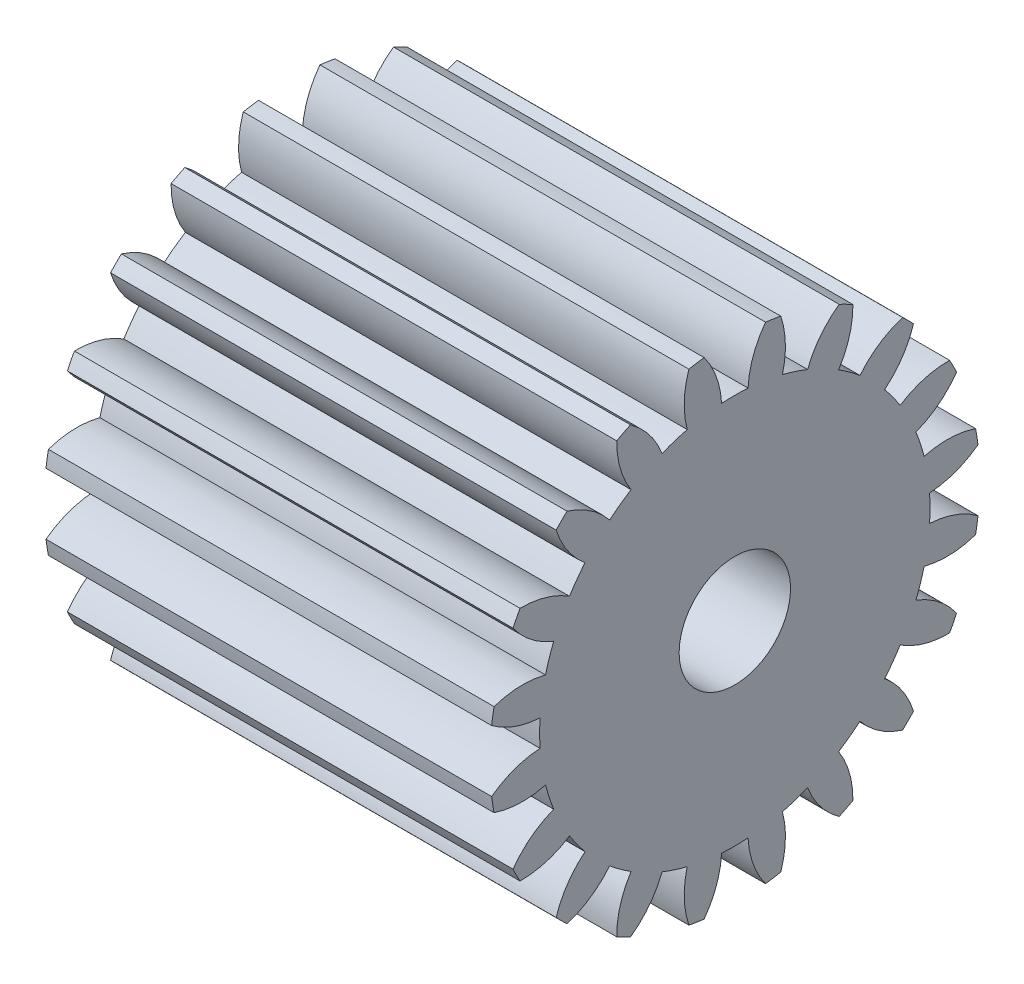
from build123d import *

# Parameters (mm, degrees)
BASPROSKE_W     = 25.4
BASPROSKE_H     = 13.97
TOOTHCUT_DEPTH  = 33.178903027
TEETHCUTS_COUNT = 20
TEETHCUTS_ANGLE = 342
BORSKE_R        = 3.175
BORE_DEPTH      = 50.8000508


with BuildPart() as part:
    # BasProSke → Base-Revolve (revolve)
    with BuildSketch(Plane(origin=(0, 0, 0), x_dir=(1, 0, 0), z_dir=(0, 1, 0)), mode=Mode.PRIVATE) as base_revolve_sk:
        with Locations((12.7, 6.985)):
            Rectangle(BASPROSKE_W, BASPROSKE_H)
    revolve(base_revolve_sk.sketch.rotate(Axis((-10, 0, 0), (1, 0, 0)), 180), axis=Axis((-10, 0, 0), (1, 0, 0)))

    # TooCutSke → ToothCut (cut, through all)
    with BuildSketch(Plane(origin=(0, 0, 0), x_dir=(0, 0, -1), z_dir=(1, 0, 0))):
        with BuildLine():
            ThreePointArc((0.753098037, 11.099681004), (0, 11.1252), (-0.753098037, 11.099681004))
            ThreePointArc((-0.753098037, 11.099681004), (-1.052888069, 12.567106713), (-1.767562739, 13.883333286))
            ThreePointArc((-1.767562739, 13.883333286), (0, 13.9954), (1.767562739, 13.883333286))
            ThreePointArc((1.767562739, 13.883333286), (1.052888069, 12.567106713), (0.753098037, 11.099681004))
        make_face()
    toothcut = extrude(amount=TOOTHCUT_DEPTH, mode=Mode.SUBTRACT)

    # TeethCuts: ToothCut ×20 about axis
    teethcuts_axis = Axis((-10, 0, 0), (1, 0, 0))
    for i in range(1, TEETHCUTS_COUNT):
        add(toothcut.rotate(teethcuts_axis, i * TEETHCUTS_ANGLE / (TEETHCUTS_COUNT - 1)), mode=Mode.SUBTRACT)

    # BorSke → Bore (cut, symmetric)
    with BuildSketch(Plane(origin=(0, 0, 0), x_dir=(0, 0, -1), z_dir=(1, 0, 0))):
        with Locations(Location((0, 0, 0), (0, 0, 180))):
            Circle(BORSKE_R)
    extrude(amount=BORE_DEPTH, both=True, mode=Mode.SUBTRACT)


solid = part.part
